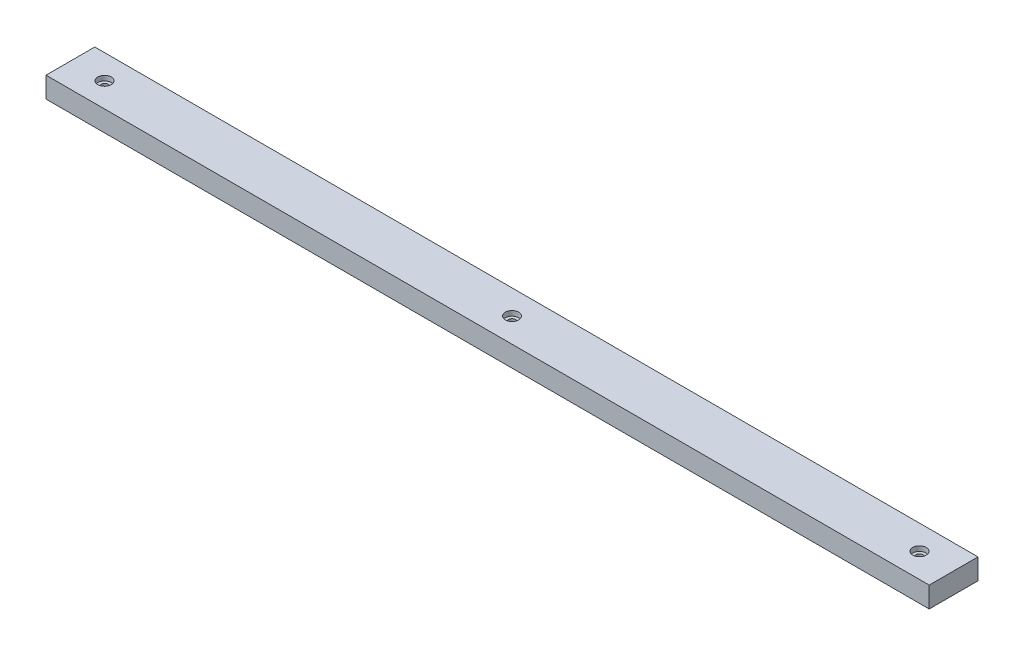
from build123d import *

# Parameters (mm, degrees)
ESQUISSE1_W                                        = 362
ESQUISSE1_H                                        = 8.5
BOSS_EXTRU_1_DEPTH                                 = 20
CHAMBRAGE_POUR_VIS_T_TE_CYLINDRIQUE_CO_D           = 3
CHAMBRAGE_POUR_VIS_T_TE_CYLINDRIQUE_CO_CBORE_D     = 5.5
CHAMBRAGE_POUR_VIS_T_TE_CYLINDRIQUE_CO_CBORE_DEPTH = 2


with BuildPart() as part:
    # Esquisse1 → Boss.-Extru.1 (new body)
    with BuildSketch(Plane.XY):
        with Locations((0, -4.25)):
            Rectangle(ESQUISSE1_W, ESQUISSE1_H)
    extrude(amount=BOSS_EXTRU_1_DEPTH)

    # Chambrage pour vis à tête cylindrique courte six pans creux M31 (through all)
    with Locations(Plane(origin=(0, 0, 0), x_dir=(1, 0, 0), z_dir=(0, 1, 0))):
        with Locations((-167, -10), (167, -10), (0, -10)):
            CounterBoreHole(CHAMBRAGE_POUR_VIS_T_TE_CYLINDRIQUE_CO_D / 2, CHAMBRAGE_POUR_VIS_T_TE_CYLINDRIQUE_CO_CBORE_D / 2, CHAMBRAGE_POUR_VIS_T_TE_CYLINDRIQUE_CO_CBORE_DEPTH)


solid = part.part
